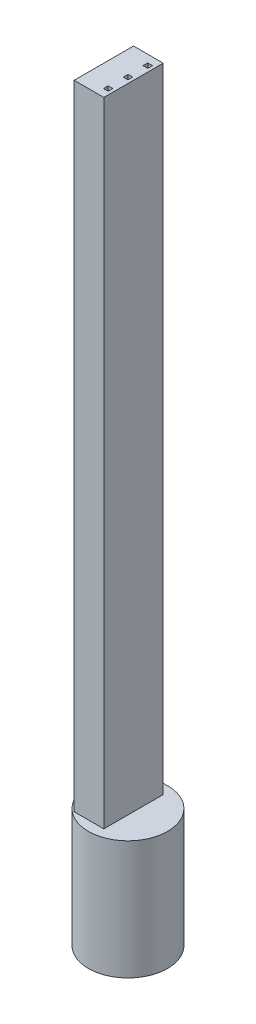
from build123d import *

# Parameters (mm, degrees)
SKETCH1_W            = 6.35
SKETCH1_H            = 19.05
SKETCH2_W            = 4.7625
SKETCH2_H            = 3.175
SKETCH2_W_2          = 0.762
SKETCH2_H_2          = 0.762
BOSS_EXTRUDE1_DEPTH  = 101.6
SKETCH6_W            = 0.762
SKETCH6_H            = 0.762
CUT_EXTRUDE2_DEPTH   = 6.35
LPATTERN1_COUNT      = 2
LPATTERN1_PITCH      = 3.175
LPATTERN1_COUNT_DIR2 = 2
LPATTERN1_PITCH_DIR2 = 3.175


with BuildPart() as part:
    # Sketch1 → Revolve1 (revolve)
    with BuildSketch(Plane.XY):
        with Locations((-3.175, 9.525)):
            Rectangle(SKETCH1_W, SKETCH1_H)
    revolve(axis=Axis((0, 19.05, 0), (0, -1, 0)))

    # Sketch2 → Boss-Extrude1 (add)
    with BuildSketch(Plane(origin=(0, 19.05, 0), x_dir=(1, 0, 0), z_dir=(0, 1, 0))):
        with Locations((-1.49225, 0)):
            Rectangle(SKETCH2_W, SKETCH2_H)
        Rectangle(SKETCH2_W_2, SKETCH2_H_2, mode=Mode.SUBTRACT)
    boss_extrude1 = extrude(amount=BOSS_EXTRUDE1_DEPTH)

    # Sketch6 → Cut-Extrude2 (cut)
    with BuildSketch(Plane(origin=(0, 19.05, 0), x_dir=(1, 0, 0), z_dir=(0, 1, 0))):
        Rectangle(SKETCH6_W, SKETCH6_H)
    cut_extrude2 = extrude(amount=-CUT_EXTRUDE2_DEPTH, mode=Mode.SUBTRACT)

    # LPattern1: Boss-Extrude1, Cut-Extrude2 2 × 2
    with Locations(*[Vector(0, 0, -1) * (i * LPATTERN1_PITCH) + Vector(0, 0, 1) * (j * LPATTERN1_PITCH_DIR2) for i in range(LPATTERN1_COUNT) for j in range(LPATTERN1_COUNT_DIR2) if (i, j) != (0, 0)]):
        add(boss_extrude1)
        add(cut_extrude2, mode=Mode.SUBTRACT)

    # Sketch4 → 1_8 NPT Tapped Hole1 (revolve, cut)
    with BuildSketch(Plane(origin=(0, 0, 0), x_dir=(0, 0, -1), z_dir=(1, 0, 0))):
        Polygon((0, 0), (0, 18.408468714), (4.2164, 15.875), (4.2164, 6.858), (4.537401096, 6.858), (4.7427388, 0), align=None)
    revolve(axis=Axis((0, -6.35, 0), (0, 1, 0)), mode=Mode.SUBTRACT)


solid = part.part
